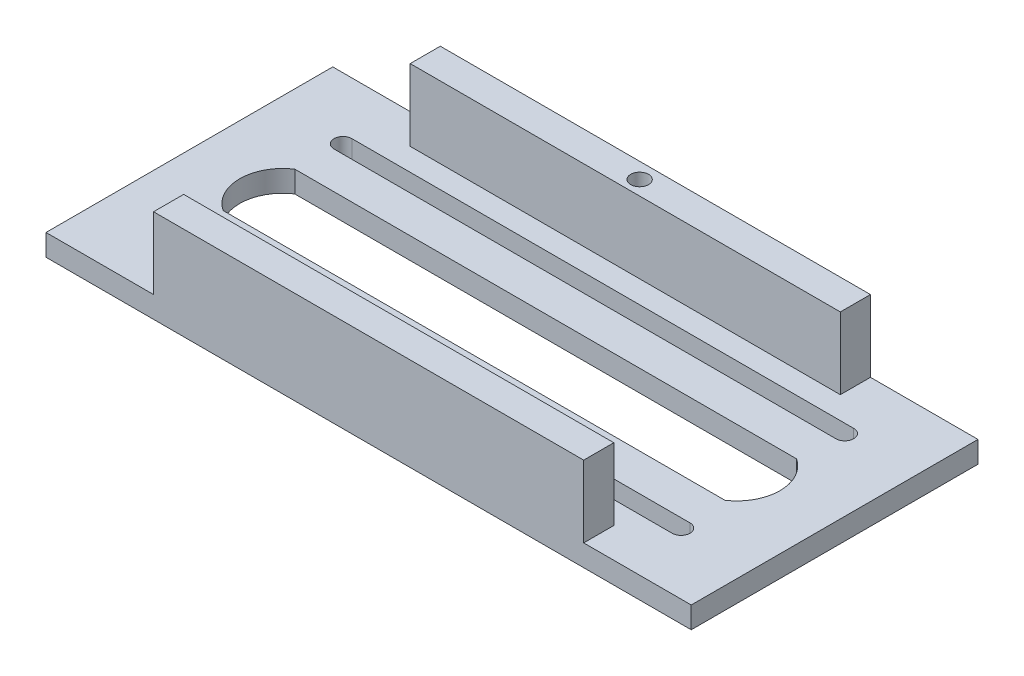
from build123d import *

# Parameters (mm, degrees)
SKETCH2_W           = 228.6
SKETCH2_H           = 101.6
BOSS_EXTRUDE1_DEPTH = 7.62
SKETCH3_W           = 152.4
SKETCH3_H           = 10.668
BOSS_EXTRUDE2_DEPTH = 25.4
CUT_EXTRUDE1_DEPTH  = 8.62
CUT_EXTRUDE2_DEPTH  = 8.62
SKETCH6_R           = 3.175
CUT_EXTRUDE3_DEPTH  = 34.02


with BuildPart() as part:
    # Sketch2 → Boss-Extrude1 (new body)
    with BuildSketch(Plane(origin=(0, 0, 0), x_dir=(1, 0, 0), z_dir=(0, 1, 0))):
        with Locations((114.3, 50.8)):
            Rectangle(SKETCH2_W, SKETCH2_H)
    extrude(amount=BOSS_EXTRUDE1_DEPTH)

    # Sketch3 → Boss-Extrude2 (add)
    with BuildSketch(Plane(origin=(0, 7.62, 0), x_dir=(1, 0, 0), z_dir=(0, 1, 0))):
        with Locations((114.3, 5.334)):
            Rectangle(SKETCH3_W, SKETCH3_H)
        with Locations((114.3, 96.266)):
            Rectangle(SKETCH3_W, SKETCH3_H)
    extrude(amount=BOSS_EXTRUDE2_DEPTH)

    # Sketch4 → Cut-Extrude1 (cut, through all)
    with BuildSketch(Plane(origin=(0, 7.62, 0), x_dir=(1, 0, 0), z_dir=(0, 1, 0))):
        with BuildLine():
            Line((25.4, 24.973599875), (203.2, 24.973599875))
            ThreePointArc((203.2, 24.973599875), (206.375, 21.798599875), (203.2, 18.623599875))
            Line((203.2, 18.623599875), (25.4, 18.623599875))
            ThreePointArc((25.4, 18.623599875), (22.225, 21.798599875), (25.4, 24.973599875))
        make_face()
        with BuildLine():
            Line((25.4, 76.626400125), (203.2, 76.626400125))
            ThreePointArc((203.2, 76.626400125), (206.375, 79.801400125), (203.2, 82.976400125))
            Line((203.2, 82.976400125), (25.4, 82.976400125))
            ThreePointArc((25.4, 82.976400125), (22.225, 79.801400125), (25.4, 76.626400125))
        make_face()
    extrude(amount=-CUT_EXTRUDE1_DEPTH, mode=Mode.SUBTRACT)

    # Sketch5 → Cut-Extrude2 (cut, through all)
    with BuildSketch(Plane(origin=(0, 7.62, 0), x_dir=(1, 0, 0), z_dir=(0, 1, 0))):
        with BuildLine():
            Line((24.632893217, 63.5), (202.432893217, 63.5))
            ThreePointArc((202.432893217, 63.5), (209.248666249, 50.8), (202.432893217, 38.1))
            Line((202.432893217, 38.1), (24.632893217, 38.1))
            ThreePointArc((24.632893217, 38.1), (17.817120184, 50.8), (24.632893217, 63.5))
        make_face()
    extrude(amount=-CUT_EXTRUDE2_DEPTH, mode=Mode.SUBTRACT)

    # Sketch6 → Cut-Extrude3 (cut, through all)
    with BuildSketch(Plane.XZ):
        with Locations((114.3, -96.012)):
            Circle(SKETCH6_R)
    extrude(amount=-CUT_EXTRUDE3_DEPTH, mode=Mode.SUBTRACT)


solid = part.part
